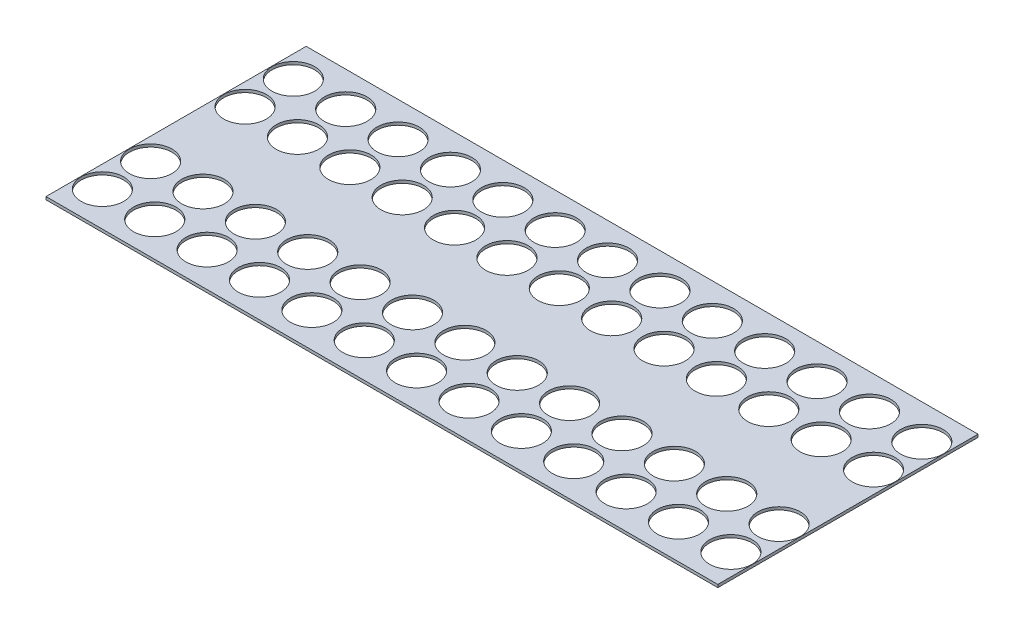
from build123d import *

# Parameters (mm, degrees)
SKETCH1_W           = 710
SKETCH1_H           = 275
SKETCH1_R           = 22.5
BOSS_EXTRUDE1_DEPTH = 3


with BuildPart() as part:
    # Sketch1 → Boss-Extrude1 (new body)
    with BuildSketch(Plane(origin=(0, 0, 0), x_dir=(1, 0, 0), z_dir=(0, 1, 0))):
        with Locations((355, 0)):
            Rectangle(SKETCH1_W, SKETCH1_H)
        with Locations((23, 100.9)):
            Circle(SKETCH1_R, mode=Mode.SUBTRACT)
        with Locations((23, 49.9)):
            Circle(SKETCH1_R, mode=Mode.SUBTRACT)
        with Locations((23, -49.9)):
            Circle(SKETCH1_R, mode=Mode.SUBTRACT)
        with Locations((23, -100.9)):
            Circle(SKETCH1_R, mode=Mode.SUBTRACT)
        with Locations((78.35, 100.9)):
            Circle(SKETCH1_R, mode=Mode.SUBTRACT)
        with Locations((78.35, 49.9)):
            Circle(SKETCH1_R, mode=Mode.SUBTRACT)
        with Locations((78.35, -49.9)):
            Circle(SKETCH1_R, mode=Mode.SUBTRACT)
        with Locations((78.35, -100.9)):
            Circle(SKETCH1_R, mode=Mode.SUBTRACT)
        with Locations((133.7, 100.9)):
            Circle(SKETCH1_R, mode=Mode.SUBTRACT)
        with Locations((133.7, 49.9)):
            Circle(SKETCH1_R, mode=Mode.SUBTRACT)
        with Locations((133.7, -49.9)):
            Circle(SKETCH1_R, mode=Mode.SUBTRACT)
        with Locations((133.7, -100.9)):
            Circle(SKETCH1_R, mode=Mode.SUBTRACT)
        with Locations((189.05, 100.9)):
            Circle(SKETCH1_R, mode=Mode.SUBTRACT)
        with Locations((189.05, 49.9)):
            Circle(SKETCH1_R, mode=Mode.SUBTRACT)
        with Locations((189.05, -49.9)):
            Circle(SKETCH1_R, mode=Mode.SUBTRACT)
        with Locations((189.05, -100.9)):
            Circle(SKETCH1_R, mode=Mode.SUBTRACT)
        with Locations((244.4, 100.9)):
            Circle(SKETCH1_R, mode=Mode.SUBTRACT)
        with Locations((244.4, 49.9)):
            Circle(SKETCH1_R, mode=Mode.SUBTRACT)
        with Locations((244.4, -49.9)):
            Circle(SKETCH1_R, mode=Mode.SUBTRACT)
        with Locations((244.4, -100.9)):
            Circle(SKETCH1_R, mode=Mode.SUBTRACT)
        with Locations((299.75, 100.9)):
            Circle(SKETCH1_R, mode=Mode.SUBTRACT)
        with Locations((299.75, 49.9)):
            Circle(SKETCH1_R, mode=Mode.SUBTRACT)
        with Locations((299.75, -49.9)):
            Circle(SKETCH1_R, mode=Mode.SUBTRACT)
        with Locations((299.75, -100.9)):
            Circle(SKETCH1_R, mode=Mode.SUBTRACT)
        with Locations((355.1, 100.9)):
            Circle(SKETCH1_R, mode=Mode.SUBTRACT)
        with Locations((355.1, 49.9)):
            Circle(SKETCH1_R, mode=Mode.SUBTRACT)
        with Locations((355.1, -49.9)):
            Circle(SKETCH1_R, mode=Mode.SUBTRACT)
        with Locations((355.1, -100.9)):
            Circle(SKETCH1_R, mode=Mode.SUBTRACT)
        with Locations((410.45, 100.9)):
            Circle(SKETCH1_R, mode=Mode.SUBTRACT)
        with Locations((410.45, 49.9)):
            Circle(SKETCH1_R, mode=Mode.SUBTRACT)
        with Locations((410.45, -49.9)):
            Circle(SKETCH1_R, mode=Mode.SUBTRACT)
        with Locations((410.45, -100.9)):
            Circle(SKETCH1_R, mode=Mode.SUBTRACT)
        with Locations((465.8, 100.9)):
            Circle(SKETCH1_R, mode=Mode.SUBTRACT)
        with Locations((465.8, 49.9)):
            Circle(SKETCH1_R, mode=Mode.SUBTRACT)
        with Locations((465.8, -49.9)):
            Circle(SKETCH1_R, mode=Mode.SUBTRACT)
        with Locations((465.8, -100.9)):
            Circle(SKETCH1_R, mode=Mode.SUBTRACT)
        with Locations((521.15, 100.9)):
            Circle(SKETCH1_R, mode=Mode.SUBTRACT)
        with Locations((521.15, 49.9)):
            Circle(SKETCH1_R, mode=Mode.SUBTRACT)
        with Locations((521.15, -49.9)):
            Circle(SKETCH1_R, mode=Mode.SUBTRACT)
        with Locations((521.15, -100.9)):
            Circle(SKETCH1_R, mode=Mode.SUBTRACT)
        with Locations((576.5, 100.9)):
            Circle(SKETCH1_R, mode=Mode.SUBTRACT)
        with Locations((576.5, 49.9)):
            Circle(SKETCH1_R, mode=Mode.SUBTRACT)
        with Locations((576.5, -49.9)):
            Circle(SKETCH1_R, mode=Mode.SUBTRACT)
        with Locations((576.5, -100.9)):
            Circle(SKETCH1_R, mode=Mode.SUBTRACT)
        with Locations((631.85, 100.9)):
            Circle(SKETCH1_R, mode=Mode.SUBTRACT)
        with Locations((631.85, 49.9)):
            Circle(SKETCH1_R, mode=Mode.SUBTRACT)
        with Locations((631.85, -49.9)):
            Circle(SKETCH1_R, mode=Mode.SUBTRACT)
        with Locations((631.85, -100.9)):
            Circle(SKETCH1_R, mode=Mode.SUBTRACT)
        with Locations((687.2, 100.9)):
            Circle(SKETCH1_R, mode=Mode.SUBTRACT)
        with Locations((687.2, 49.9)):
            Circle(SKETCH1_R, mode=Mode.SUBTRACT)
        with Locations((687.2, -49.9)):
            Circle(SKETCH1_R, mode=Mode.SUBTRACT)
        with Locations((687.2, -100.9)):
            Circle(SKETCH1_R, mode=Mode.SUBTRACT)
    extrude(amount=BOSS_EXTRUDE1_DEPTH)


solid = part.part
